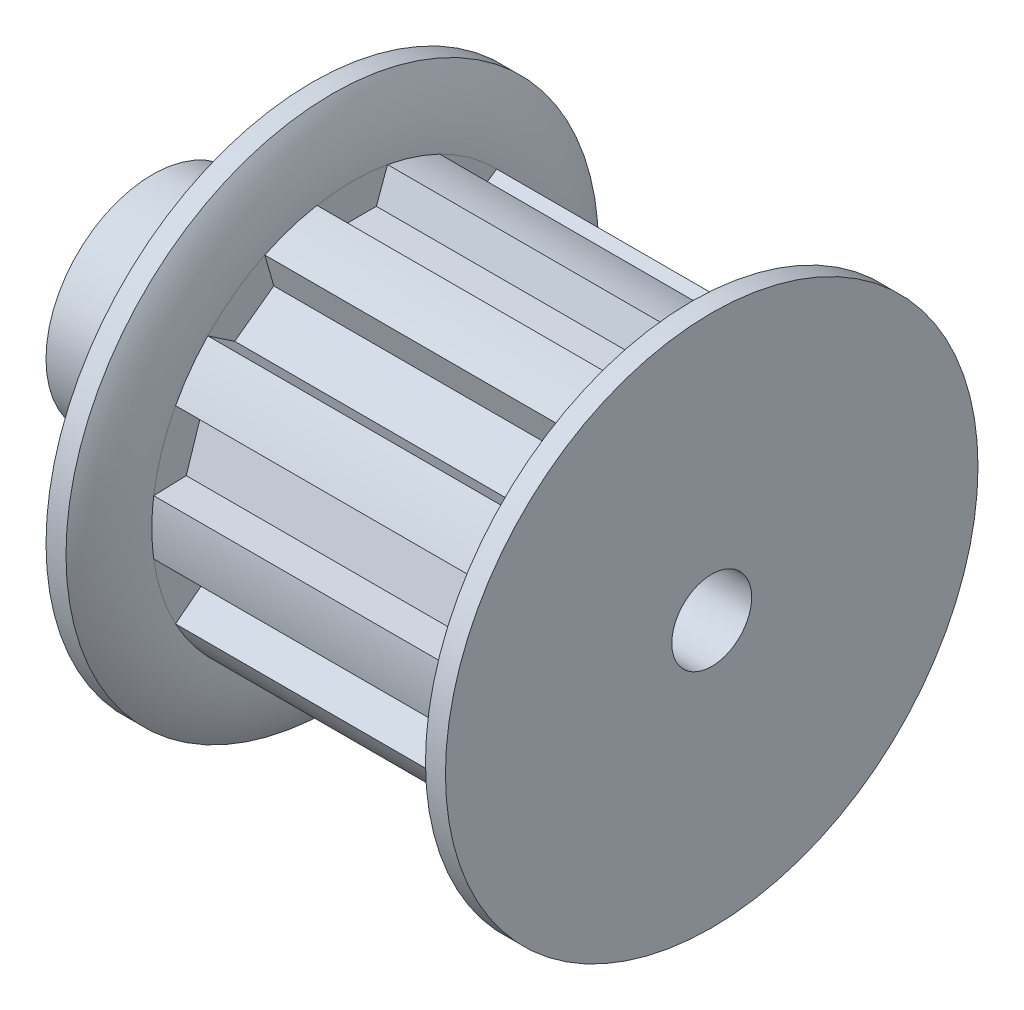
from build123d import *

# Parameters (mm, degrees)
CUT_EXTRUDE1_START  = -3
CUT_EXTRUDE1_DEPTH  = 12
CIRPATTERN1_COUNT   = 10
BOSS_EXTRUDE1_START = 10.5
SKETCH7_R           = 2.383452373
SKETCH7_R_2         = 1.5
BOSS_EXTRUDE1_DEPTH = 21


with BuildPart() as part:
    # Sketch6 → Revolve1 (revolve)
    with BuildSketch(Plane.XY):
        with BuildLine():
            Line((9.75, 10), (10.5, 10))
            Line((10.5, 10), (10.5, 2))
            Line((10.5, 2), (-10.5, 2))
            Line((-10.5, 2), (-10.5, 4))
            Line((-10.5, 4), (-4.5, 4))
            Line((-4.5, 4), (-4.5, 10))
            Line((-4.5, 10), (-3.75, 10))
            ThreePointArc((-3.75, 10), (-3.191617437, 8.818070474), (-3, 7.525))
            Line((-3, 7.525), (9, 7.525))
            ThreePointArc((9, 7.525), (9.191617437, 8.818070474), (9.75, 10))
        make_face()
    revolve(axis=Axis((-10.5, 0, 0), (1, 0, 0)))

    # Sketch3 → Cut-Extrude1 (cut)
    with BuildSketch(Plane(origin=(0, 0, 0), x_dir=(0, 0, -1), z_dir=(1, 0, 0)).offset(CUT_EXTRUDE1_START)):
        with BuildLine():
            Line((-1.325, 7.407428704), (-0.907223869, 6.259598218))
            Line((-0.907223869, 6.259598218), (0.907223869, 6.259598218))
            Line((0.907223869, 6.259598218), (1.325, 7.407428704))
            ThreePointArc((1.325, 7.407428704), (0, 7.525), (-1.325, 7.407428704))
        make_face()
    cut_extrude1 = extrude(amount=CUT_EXTRUDE1_DEPTH, mode=Mode.SUBTRACT)

    # CirPattern1: Cut-Extrude1 ×10 about axis
    cirpattern1_axis = Axis((0, 0, 0), (1, 0, 0))
    for i in range(1, CIRPATTERN1_COUNT):
        add(cut_extrude1.rotate(cirpattern1_axis, i * 360 / CIRPATTERN1_COUNT), mode=Mode.SUBTRACT)

    # Sketch7 → Boss-Extrude1 (add)
    with BuildSketch(Plane(origin=(0, 0, 0), x_dir=(0, 0, -1), z_dir=(1, 0, 0)).offset(BOSS_EXTRUDE1_START)):
        Circle(SKETCH7_R)
        Circle(SKETCH7_R_2, mode=Mode.SUBTRACT)
    extrude(amount=-BOSS_EXTRUDE1_DEPTH)


solid = part.part
